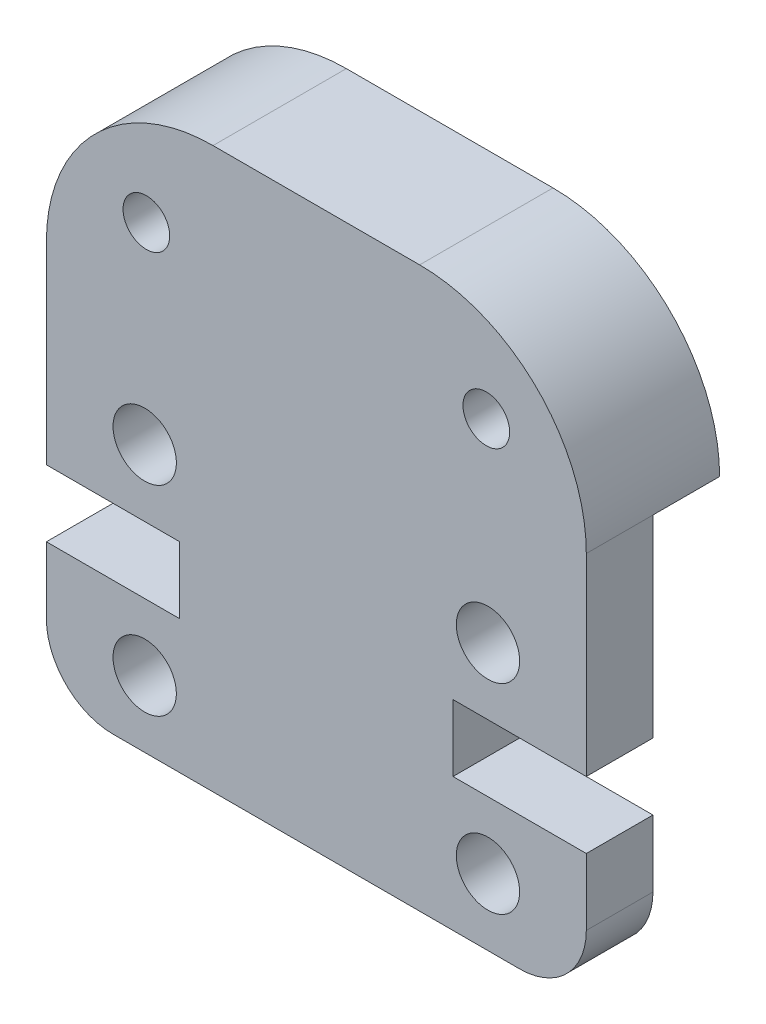
from build123d import *

# Parameters (mm, degrees)
SKETCH1_R           = 0.95
SKETCH1_R_2         = 0.7
BOSS_EXTRUDE1_DEPTH = 4
SKETCH2_W           = 16.2
SKETCH2_H           = 11.795
CUT_EXTRUDE1_DEPTH  = 2


with BuildPart() as part:
    # Sketch1 → Boss-Extrude1 (new body)
    with BuildSketch(Plane.XY):
        with BuildLine():
            Line((0, 6), (0, 11.795))
            ThreePointArc((0, 11.795), (1.464466094, 15.330533906), (5, 16.795))
            Line((5, 16.795), (11.2, 16.795))
            ThreePointArc((11.2, 16.795), (14.735533906, 15.330533906), (16.2, 11.795))
            Line((16.2, 11.795), (16.2, 6))
            Line((16.2, 6), (12.2, 6))
            Line((12.2, 6), (12.2, 4))
            Line((12.2, 4), (16.2, 4))
            Line((16.2, 4), (16.2, 2))
            ThreePointArc((16.2, 2), (15.614213562, 0.585786438), (14.2, 0))
            Line((14.2, 0), (2, 0))
            ThreePointArc((2, 0), (0.585786438, 0.585786438), (0, 2))
            Line((0, 2), (0, 4))
            Line((0, 4), (4, 4))
            Line((4, 4), (4, 6))
            Line((4, 6), (0, 6))
        make_face()
        with Locations((13.25, 2)):
            Circle(SKETCH1_R, mode=Mode.SUBTRACT)
        with Locations((13.25, 8)):
            Circle(SKETCH1_R, mode=Mode.SUBTRACT)
        with Locations((3, 13.795)):
            Circle(SKETCH1_R_2, mode=Mode.SUBTRACT)
        with Locations((13.2, 13.795)):
            Circle(SKETCH1_R_2, mode=Mode.SUBTRACT)
        with Locations((2.95, 8)):
            Circle(SKETCH1_R, mode=Mode.SUBTRACT)
        with Locations((2.95, 2)):
            Circle(SKETCH1_R, mode=Mode.SUBTRACT)
    extrude(amount=BOSS_EXTRUDE1_DEPTH)

    # Sketch2 → Cut-Extrude1 (cut)
    with BuildSketch(Plane.XY):
        with Locations((8.1, 5.8975)):
            Rectangle(SKETCH2_W, SKETCH2_H)
    extrude(amount=CUT_EXTRUDE1_DEPTH, mode=Mode.SUBTRACT)


solid = part.part
